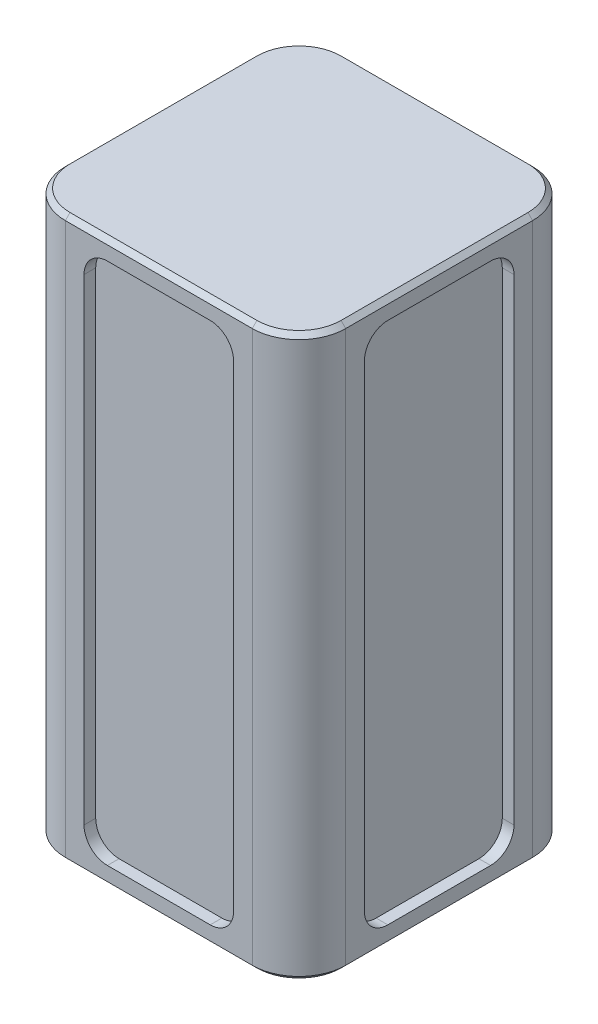
from build123d import *

# Parameters (mm, degrees)
BOSS_EXTRUDE1_DEPTH = 20
BOSS_EXTRUDE2_START = -100
SKETCH1_3_R         = 25
BOSS_EXTRUDE2_DEPTH = 100
CUT_EXTRUDE1_DEPTH  = 2.5
CIRPATTERN1_COUNT   = 4
CHAMFER1_SIZE       = 1


with BuildPart() as part:
    # Sketch1 → Boss-Extrude1 (new body)
    with BuildSketch(Plane(origin=(0, 0, 0), x_dir=(1, 0, 0), z_dir=(0, 1, 0))):
        with BuildLine():
            Line((-65.280898876, -14.157303371), (-25.280898876, -14.157303371))
            ThreePointArc((-25.280898876, -14.157303371), (-18.209831065, -11.228371183), (-15.280898876, -4.157303371))
            Line((-15.280898876, -4.157303371), (-15.280898876, 35.842696629))
            ThreePointArc((-15.280898876, 35.842696629), (-18.209831065, 42.913764441), (-25.280898876, 45.842696629))
            Line((-25.280898876, 45.842696629), (-65.280898876, 45.842696629))
            ThreePointArc((-65.280898876, 45.842696629), (-72.351966688, 42.913764441), (-75.280898876, 35.842696629))
            Line((-75.280898876, 35.842696629), (-75.280898876, -4.157303371))
            ThreePointArc((-75.280898876, -4.157303371), (-72.351966688, -11.228371183), (-65.280898876, -14.157303371))
        make_face()
    extrude(amount=BOSS_EXTRUDE1_DEPTH)

    # Sketch1_3 → Boss-Extrude2 (add)
    with BuildSketch(Plane(origin=(0, 0, 0), x_dir=(1, 0, 0), z_dir=(0, 1, 0)).offset(BOSS_EXTRUDE2_START)):
        with BuildLine():
            Line((-65.280898876, -14.157303371), (-25.280898876, -14.157303371))
            ThreePointArc((-25.280898876, -14.157303371), (-18.209831065, -11.228371183), (-15.280898876, -4.157303371))
            Line((-15.280898876, -4.157303371), (-15.280898876, 35.842696629))
            ThreePointArc((-15.280898876, 35.842696629), (-18.209831065, 42.913764441), (-25.280898876, 45.842696629))
            Line((-25.280898876, 45.842696629), (-65.280898876, 45.842696629))
            ThreePointArc((-65.280898876, 45.842696629), (-72.351966688, 42.913764441), (-75.280898876, 35.842696629))
            Line((-75.280898876, 35.842696629), (-75.280898876, -4.157303371))
            ThreePointArc((-75.280898876, -4.157303371), (-72.351966688, -11.228371183), (-65.280898876, -14.157303371))
        make_face()
        with Locations((-45.280898876, 15.842696629)):
            Circle(SKETCH1_3_R, mode=Mode.SUBTRACT)
    extrude(amount=BOSS_EXTRUDE2_DEPTH)

    # Sketch2 → Cut-Extrude1 (cut)
    with BuildSketch(Plane(origin=(0, 0, -45.842696629), x_dir=(-1, 0, 0), z_dir=(0, 0, -1))):
        with BuildLine():
            Line((61.280898876, -91), (61.280898876, 11))
            ThreePointArc((61.280898876, 11), (59.816432782, 14.535533906), (56.280898876, 16))
            Line((56.280898876, 16), (34.280898876, 16))
            ThreePointArc((34.280898876, 16), (30.74536497, 14.535533906), (29.280898876, 11))
            Line((29.280898876, 11), (29.280898876, -91))
            ThreePointArc((29.280898876, -91), (30.74536497, -94.535533906), (34.280898876, -96))
            Line((34.280898876, -96), (56.280898876, -96))
            ThreePointArc((56.280898876, -96), (59.816432782, -94.535533906), (61.280898876, -91))
        make_face()
    cut_extrude1 = extrude(amount=-CUT_EXTRUDE1_DEPTH, mode=Mode.SUBTRACT)

    # CirPattern1: Cut-Extrude1 ×4 about axis
    cirpattern1_axis = Axis((-45.280898876, -100, -15.842696629), (0, 1, 0))
    for i in range(1, CIRPATTERN1_COUNT):
        add(cut_extrude1.rotate(cirpattern1_axis, i * 360 / CIRPATTERN1_COUNT), mode=Mode.SUBTRACT)

    # Chamfer1
    chamfer1_edges = [part.edges().sort_by_distance(p)[0] for p in [
        (-70.280898876, -100, -15.842696629),
        (-75.280898876, -100, -15.842696629),
        (-72.351966688, -100, -42.913764441),
        (-45.280898876, -100, -45.842696629),
        (-18.209831065, -100, -42.913764441),
        (-15.280898876, -100, -15.842696629),
        (-18.209831065, -100, 11.228371183),
        (-45.280898876, -100, 14.157303371),
        (-72.351966688, -100, 11.228371183),
        (-18.209831065, 20, 11.228371183),
        (-18.209831065, 20, -42.913764441),
        (-72.351966688, 20, -42.913764441),
        (-72.351966688, 20, 11.228371183),
        (-45.280898876, 20, -45.842696629),
        (-15.280898876, 20, -15.842696629),
        (-45.280898876, 20, 14.157303371),
        (-75.280898876, 20, -15.842696629),
    ]]
    chamfer(chamfer1_edges, length=CHAMFER1_SIZE)


solid = part.part
